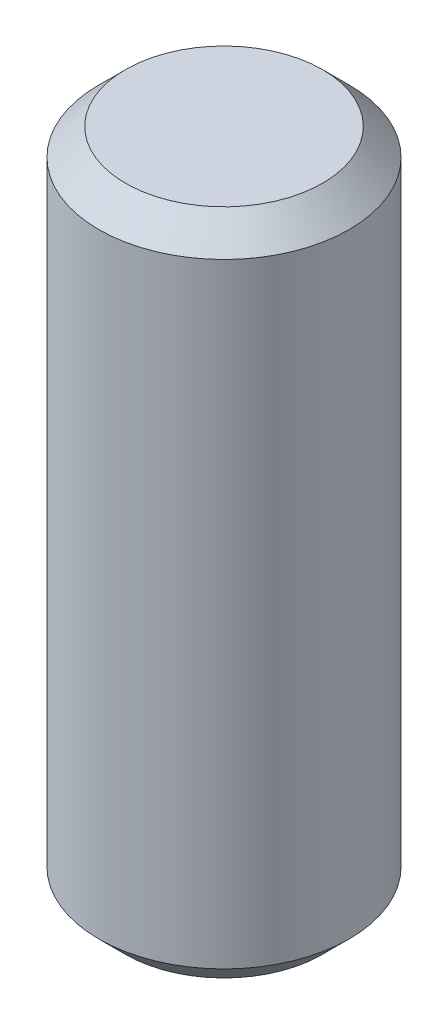
from build123d import *

# Parameters (mm, degrees)
SKETCH1_W     = 1.190625
SKETCH1_H     = 6.35
CHAMFER1_SIZE = 0.254


with BuildPart() as part:
    # Sketch1 → Revolve1 (revolve)
    with BuildSketch(Plane.XY):
        with Locations((0.5953125, 0)):
            Rectangle(SKETCH1_W, SKETCH1_H)
    revolve(axis=Axis((0, 0.760475273, 0), (0, -1, 0)))

    # Chamfer1
    chamfer1_edges = [part.edges().sort_by_distance(p)[0] for p in [
        (-1.190625, 3.175, 0),
        (-1.190625, -3.175, 0),
    ]]
    chamfer(chamfer1_edges, length=CHAMFER1_SIZE)


solid = part.part
